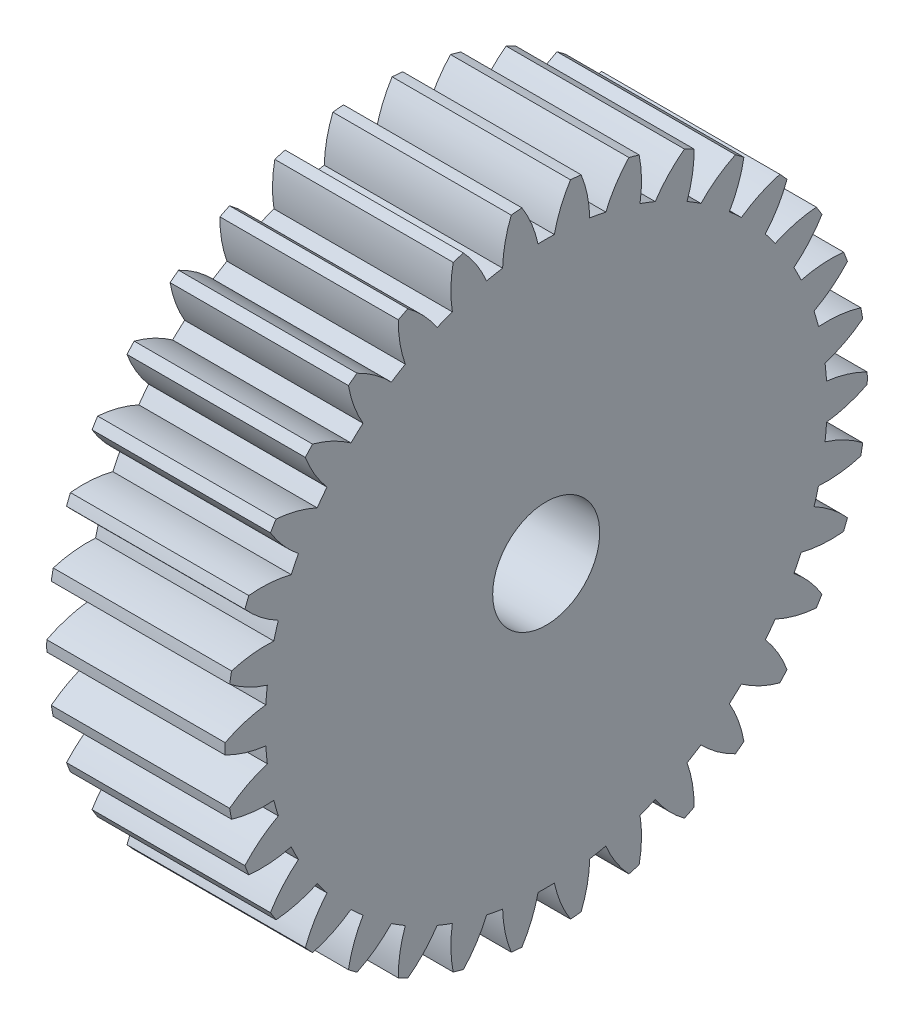
from build123d import *

# Parameters (mm, degrees)
BASPROSKE_W     = 10
BASPROSKE_H     = 18
TOOTHCUT_DEPTH  = 28.349588662
TEETHCUTS_COUNT = 34
TEETHCUTS_ANGLE = 349.411764706
BORSKE_R        = 3
BORE_DEPTH      = 50.0000508


with BuildPart() as part:
    # BasProSke → Base-Revolve (revolve)
    with BuildSketch(Plane(origin=(0, 0, 0), x_dir=(1, 0, 0), z_dir=(0, 1, 0)), mode=Mode.PRIVATE) as base_revolve_sk:
        with Locations((5, 9)):
            Rectangle(BASPROSKE_W, BASPROSKE_H)
    revolve(base_revolve_sk.sketch.rotate(Axis((-10, 0, 0), (1, 0, 0)), 180), axis=Axis((-10, 0, 0), (1, 0, 0)))

    # TooCutSke → ToothCut (cut, through all)
    with BuildSketch(Plane(origin=(0, 0, 0), x_dir=(0, 0, -1), z_dir=(1, 0, 0))):
        with BuildLine():
            ThreePointArc((0.458149848, 15.742334634), (0, 15.749), (-0.458149848, 15.742334634))
            ThreePointArc((-0.458149848, 15.742334634), (-0.818018246, 16.898604037), (-1.377276242, 17.972705843))
            ThreePointArc((-1.377276242, 17.972705843), (0, 18.0254), (1.377276242, 17.972705843))
            ThreePointArc((1.377276242, 17.972705843), (0.818018246, 16.898604037), (0.458149848, 15.742334634))
        make_face()
    toothcut = extrude(amount=TOOTHCUT_DEPTH, mode=Mode.SUBTRACT)

    # TeethCuts: ToothCut ×34 about axis
    teethcuts_axis = Axis((-10, 0, 0), (1, 0, 0))
    for i in range(1, TEETHCUTS_COUNT):
        add(toothcut.rotate(teethcuts_axis, i * TEETHCUTS_ANGLE / (TEETHCUTS_COUNT - 1)), mode=Mode.SUBTRACT)

    # BorSke → Bore (cut, symmetric)
    with BuildSketch(Plane(origin=(0, 0, 0), x_dir=(0, 0, -1), z_dir=(1, 0, 0))):
        with Locations(Location((0, 0, 0), (0, 0, 180))):
            Circle(BORSKE_R)
    extrude(amount=BORE_DEPTH, both=True, mode=Mode.SUBTRACT)


solid = part.part
